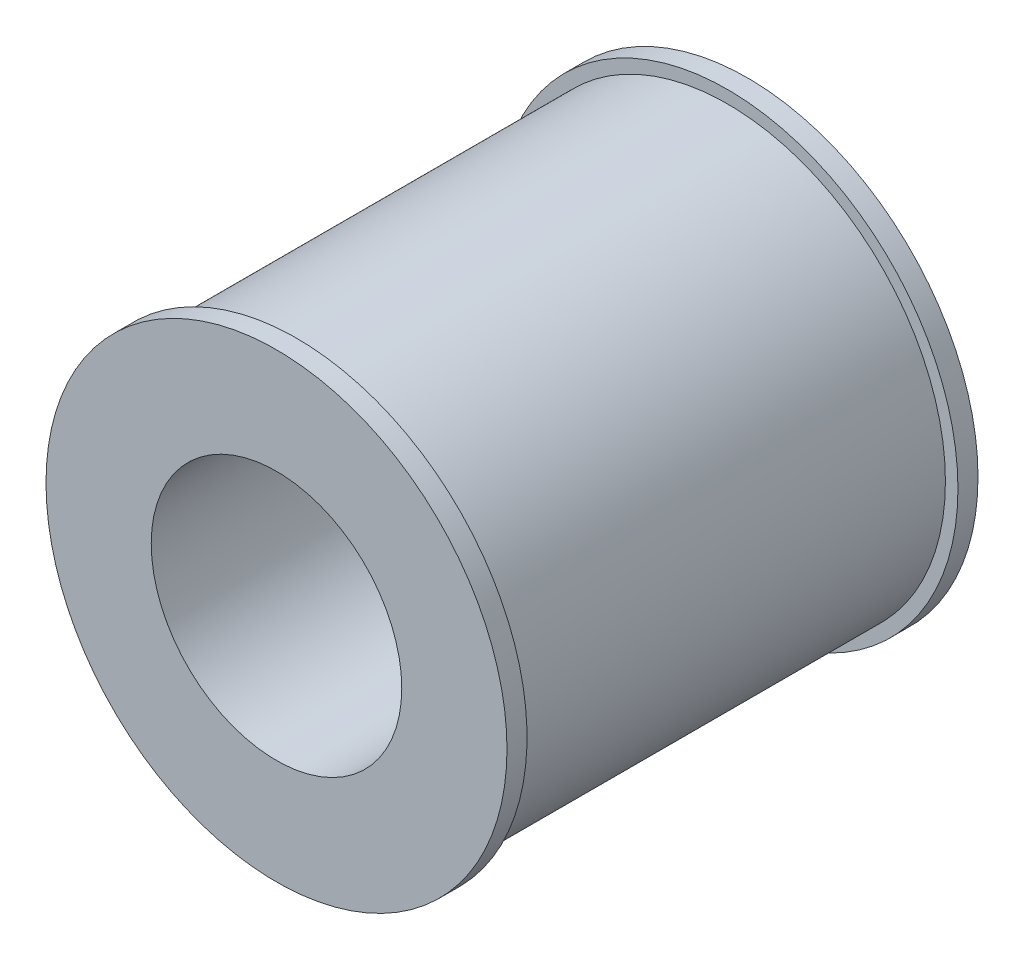
from build123d import *

# Parameters (mm, degrees)
SKETCH_1_R      = 23
SKETCH_1_R_2    = 12.5
EXTRUDE_1_DEPTH = 47
SKETCH_2_W      = 43
SKETCH_2_H      = 2.5


with BuildPart() as part:
    # Эскиз1 → Бобышка-Вытянуть1 (new body)
    with BuildSketch(Plane.XY):
        Circle(SKETCH_1_R)
        Circle(SKETCH_1_R_2, mode=Mode.SUBTRACT)
    extrude(amount=EXTRUDE_1_DEPTH)

    # Эскиз2 → Вырез-Повернуть1 (revolve, cut)
    with BuildSketch(Plane(origin=(0, 0, 0), x_dir=(0, 0, -1), z_dir=(1, 0, 0))):
        with Locations((-23.5, 23)):
            Rectangle(SKETCH_2_W, SKETCH_2_H)
    revolve(axis=Axis((0, 0, 47), (0, 0, -1)), mode=Mode.SUBTRACT)


solid = part.part
